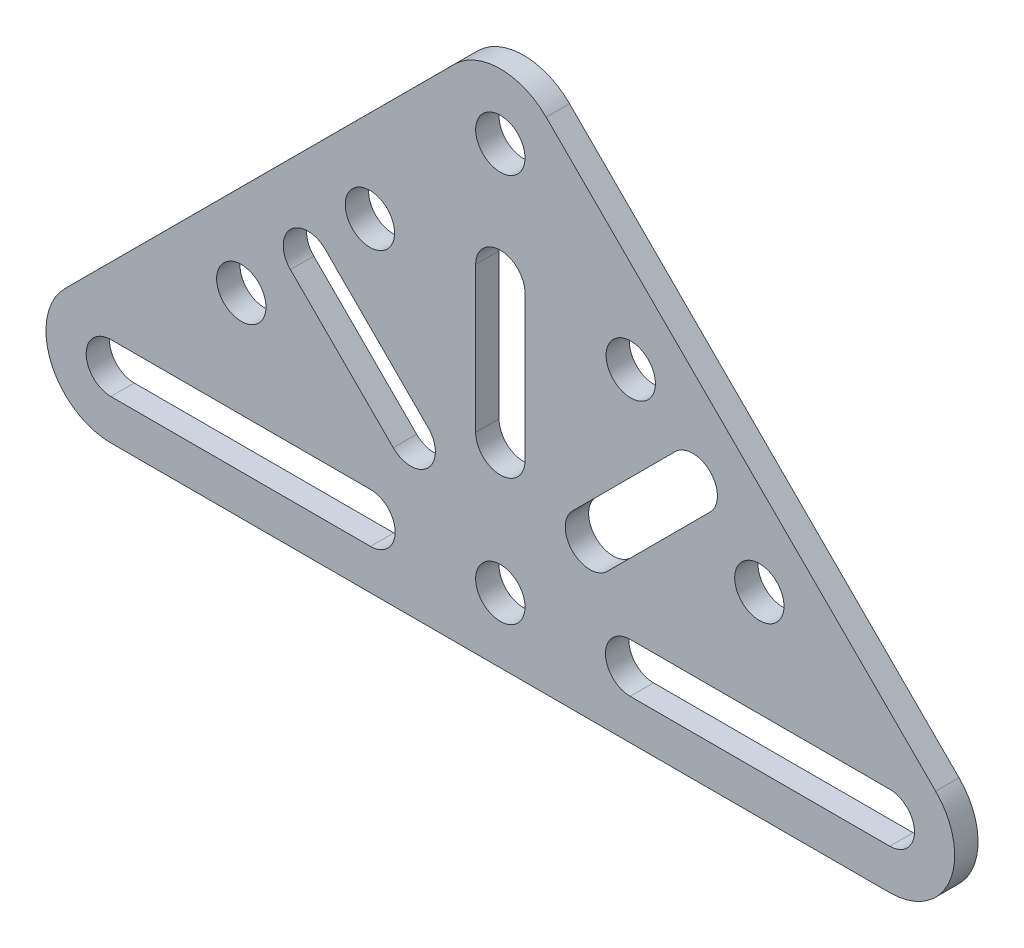
from build123d import *

# Parameters (mm, degrees)
BOSS_EXTRUDE1_DEPTH = 2.286
SKETCH2_R           = 2.413
CUT_EXTRUDE1_DEPTH  = 3.286
CUT_EXTRUDE2_DEPTH  = 3.286
CUT_EXTRUDE3_DEPTH  = 3.286
CIRPATTERN1_COUNT   = 3
CIRPATTERN1_ANGLE   = 90


with BuildPart() as part:
    # Sketch1 → Boss-Extrude1 (new body)
    with BuildSketch(Plane.XY):
        with BuildLine():
            Line((-42.58732985, 4.492924528), (-4.48732985, 42.545481657))
            ThreePointArc((-4.48732985, 42.545481657), (0, 44.402557128), (4.48732985, 42.545481657))
            Line((4.48732985, 42.545481657), (42.58732985, 4.492924528))
            ThreePointArc((42.58732985, 4.492924528), (43.967391701, -2.428212228), (38.1, -6.35))
            Line((38.1, -6.35), (-38.1, -6.35))
            ThreePointArc((-38.1, -6.35), (-43.967391701, -2.428212228), (-42.58732985, 4.492924528))
        make_face()
    extrude(amount=BOSS_EXTRUDE1_DEPTH)

    # Sketch2 → Cut-Extrude1 (cut, through all)
    with BuildSketch(Plane.XY.offset(2.286)):
        Circle(SKETCH2_R)
        with Locations((0, 38.052557128)):
            Circle(SKETCH2_R)
        with Locations((-25.34009434, 12.744016774)):
            Circle(SKETCH2_R)
        with Locations((25.34009434, 12.744016774)):
            Circle(SKETCH2_R)
        with Locations((-12.75990566, 25.308540354)):
            Circle(SKETCH2_R)
        with Locations((12.75990566, 25.308540354)):
            Circle(SKETCH2_R)
    extrude(amount=-CUT_EXTRUDE1_DEPTH, mode=Mode.SUBTRACT)

    # Sketch3 → Cut-Extrude2 (cut, through all)
    with BuildSketch(Plane.XY.offset(2.286)):
        with BuildLine():
            Line((-38.1, 2.413), (-12.7, 2.413))
            ThreePointArc((-12.7, 2.413), (-10.287, 0), (-12.7, -2.413))
            Line((-12.7, -2.413), (-38.1, -2.413))
            ThreePointArc((-38.1, -2.413), (-40.513, 0), (-38.1, 2.413))
        make_face()
    cut_extrude2 = extrude(amount=-CUT_EXTRUDE2_DEPTH, mode=Mode.SUBTRACT)

    # Mirror1: Cut-Extrude2 across plane
    add(cut_extrude2.mirror(Plane(origin=(0, 0, 0), x_dir=(0, 0, 1), z_dir=(1, 0, 0))), mode=Mode.SUBTRACT)

    # Sketch4 → Cut-Extrude3 (cut, through all)
    with BuildSketch(Plane.XY.offset(2.286)):
        with BuildLine():
            Line((-17.118826926, 20.531324252), (-7.06094007, 10.473437396))
            ThreePointArc((-7.06094007, 10.473437396), (-7.06094007, 7.06094007), (-10.473437396, 7.06094007))
            Line((-10.473437396, 7.06094007), (-20.531324252, 17.118826926))
            ThreePointArc((-20.531324252, 17.118826926), (-20.531324252, 20.531324252), (-17.118826926, 20.531324252))
        make_face()
    cut_extrude3 = extrude(amount=-CUT_EXTRUDE3_DEPTH, mode=Mode.SUBTRACT)

    # CirPattern1: Cut-Extrude3 ×3 about axis
    cirpattern1_axis = Axis((0, 0, 0), (0, 0, -1))
    for i in range(1, CIRPATTERN1_COUNT):
        add(cut_extrude3.rotate(cirpattern1_axis, i * CIRPATTERN1_ANGLE / (CIRPATTERN1_COUNT - 1)), mode=Mode.SUBTRACT)


solid = part.part
